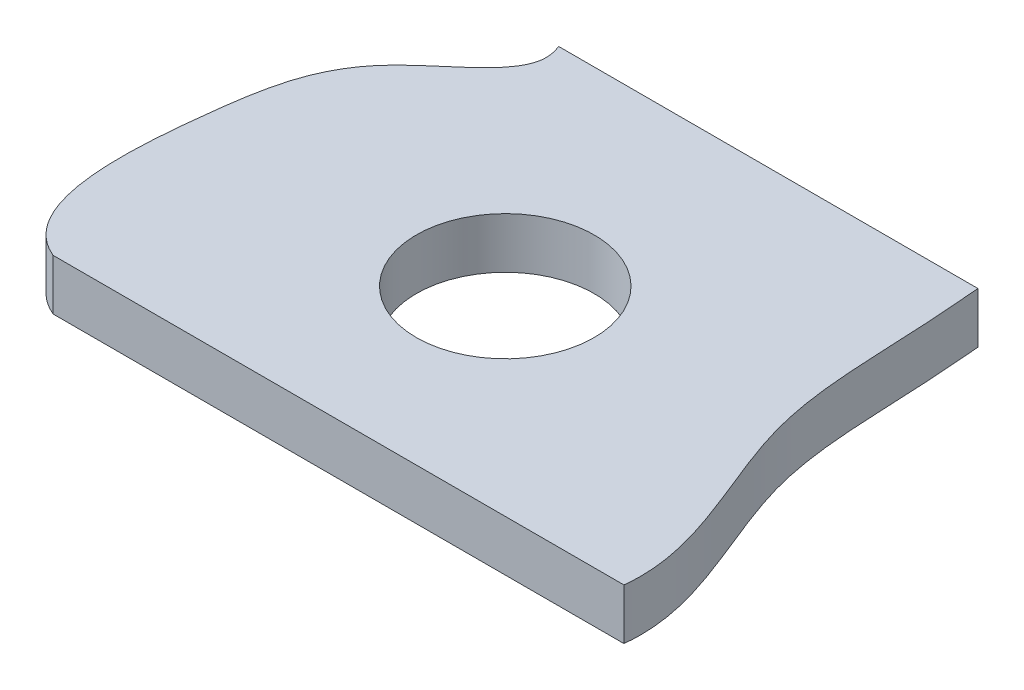
from build123d import *

# Parameters (mm, degrees)
DODANIE_WYCI_GNI_CIE1_DEPTH = 3
SZKIC2_R                    = 5.25
WYTNIJ_WYCI_GNI_CIE1_DEPTH  = 123.478678077
SZKIC3_W                    = 83.042343976
SZKIC3_H                    = 22.425434336
SZKIC3_W_2                  = 92.40199983
SZKIC3_H_2                  = 23.262955651
WYTNIJ_WYCI_GNI_CIE2_DEPTH  = 123.478678077
WYTNIJ_WYCI_GNI_CIE3_DEPTH  = 114.371150202


with BuildPart() as part:
    # Szkic1 → Dodanie-wyciągnięcie1 (new body)
    with BuildSketch(Plane(origin=(0, 0, 0), x_dir=(1, 0, 0), z_dir=(0, 1, 0))):
        with BuildLine():
            Line((-97.678150888, 49.4149367), (-32.744802343, 49.4149367))
            add(Edge.make_bspline(
                [(-32.744802343, 49.4149367), (-29.306315805, 38.482449345), (-35.086079974, 19.443677378), (-46.815707035, -0.452000217), (-49.516641207, -11.467220133), (-49.715376383, -12.36868324)],
                knots=[0.154589074, 0.154589074, 0.154589074, 0.154589074, 0.39168588, 0.61157723, 0.631041789, 0.631041789, 0.631041789, 0.631041789], degree=3))
            Line((-49.715376383, -12.36868324), (-112.027633116, -12.36868324))
            add(Edge.make_bspline(
                [(-97.678150888, 49.4149367), (-95.996907517, 42.817556452), (-98.213660437, 28.328196325), (-109.215623339, 9.191600555), (-111.919105273, -6.718294499), (-112.027633116, -12.36868324)],
                knots=[0.127638687, 0.127638687, 0.127638687, 0.127638687, 0.284871496, 0.500245721, 0.624008673, 0.624008673, 0.624008673, 0.624008673], degree=3))
        make_face()
    extrude(amount=DODANIE_WYCI_GNI_CIE1_DEPTH)

    # Szkic2 → Wytnij-wyciągnięcie1 (cut, through all)
    with BuildSketch(Plane(origin=(0, 3, 0), x_dir=(1, 0, 0), z_dir=(0, 1, 0))):
        with Locations(Location((-73.202778656, 17.886796147, 0), (0, 0, 270))):
            Circle(SZKIC2_R)
    extrude(amount=-WYTNIJ_WYCI_GNI_CIE1_DEPTH, mode=Mode.SUBTRACT)

    # Szkic3 → Wytnij-wyciągnięcie2 (cut, through all)
    with BuildSketch(Plane(origin=(0, 3, 0), x_dir=(1, 0, 0), z_dir=(0, 1, 0))):
        with Locations((-62.244564273, 42.931839176)):
            Rectangle(SZKIC3_W, SZKIC3_H)
        with Locations((-68.037284909, -5.510245727)):
            Rectangle(SZKIC3_W_2, SZKIC3_H_2)
    extrude(amount=-WYTNIJ_WYCI_GNI_CIE2_DEPTH, mode=Mode.SUBTRACT)

    # Szkic4 → Wytnij-wyciągnięcie3 (cut, through all)
    with BuildSketch(Plane(origin=(0, 3, 0), x_dir=(1, 0, 0), z_dir=(0, 1, 0))):
        with BuildLine():
            add(Edge.make_bspline(
                [(-88.689938792, 36.010164682), (-86.071156922, 34.618848613), (-81.089784858, 30.465171833), (-89.644619421, 25.502930729), (-91.094282475, 17.320923853), (-91.890518911, 4.656814481), (-70.345884336, 7.408238477), (-112.625080918, -8.466168712), (-128.254843762, 14.531836441), (-112.47359997, 31.235119166), (-98.588015331, 41.268851209), (-88.689938792, 36.010164682)],
                knots=[0, 0, 0, 0, 0.056310149, 0.105139867, 0.166932459, 0.258637906, 0.305170294, 0.520996128, 0.678649021, 0.787167396, 1, 1, 1, 1], degree=3))
        make_face()
        with BuildLine():
            add(Edge.make_bspline(
                [(-58.506782582, 38.587883821), (-59.676552515, 36.005094764), (-58.575510558, 28.258639934), (-58.925436397, 17.111965112), (-49.705448185, 4.127794868), (-72.040088465, -9.964706752), (-44.500598429, -4.631349285), (-29.373358451, 0.777563949), (-22.973161664, 21.590397636), (-30.322336493, 42.955036515), (-55.380407315, 45.490752157), (-58.506782582, 38.587883821)],
                knots=[0, 0, 0, 0, 0.066886355, 0.137581529, 0.239375905, 0.330501418, 0.448637218, 0.557955025, 0.707331232, 0.821236773, 1, 1, 1, 1], degree=3))
        make_face()
    extrude(amount=-WYTNIJ_WYCI_GNI_CIE3_DEPTH, mode=Mode.SUBTRACT)


solid = part.part
